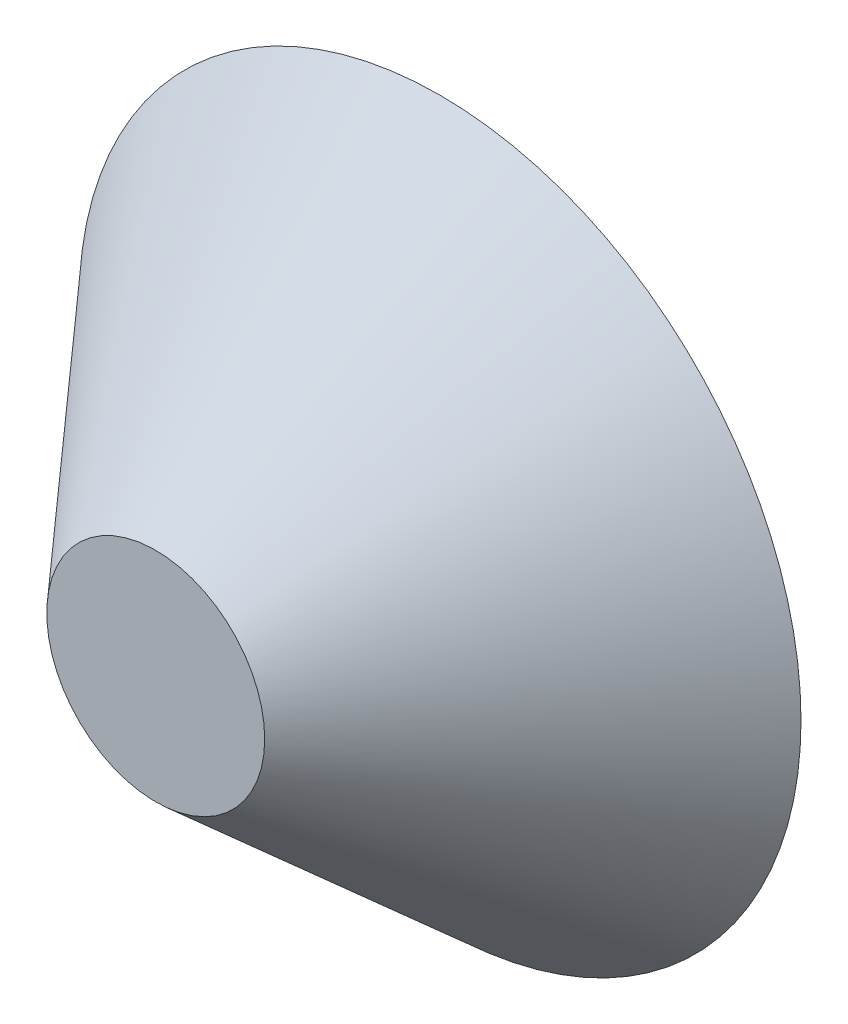
from build123d import *

# Parameters (mm, degrees)
SKETCH1_R = 38.1
SKETCH2_R = 11.5


with BuildPart() as part:
    # Sketch1 → Loft1 section 0
    with BuildSketch(Plane.XY):
        Circle(SKETCH1_R)
    # Sketch2 → Loft1 section 1
    with BuildSketch(Plane.XY.offset(30)):
        Circle(SKETCH2_R)
    loft()


solid = part.part
